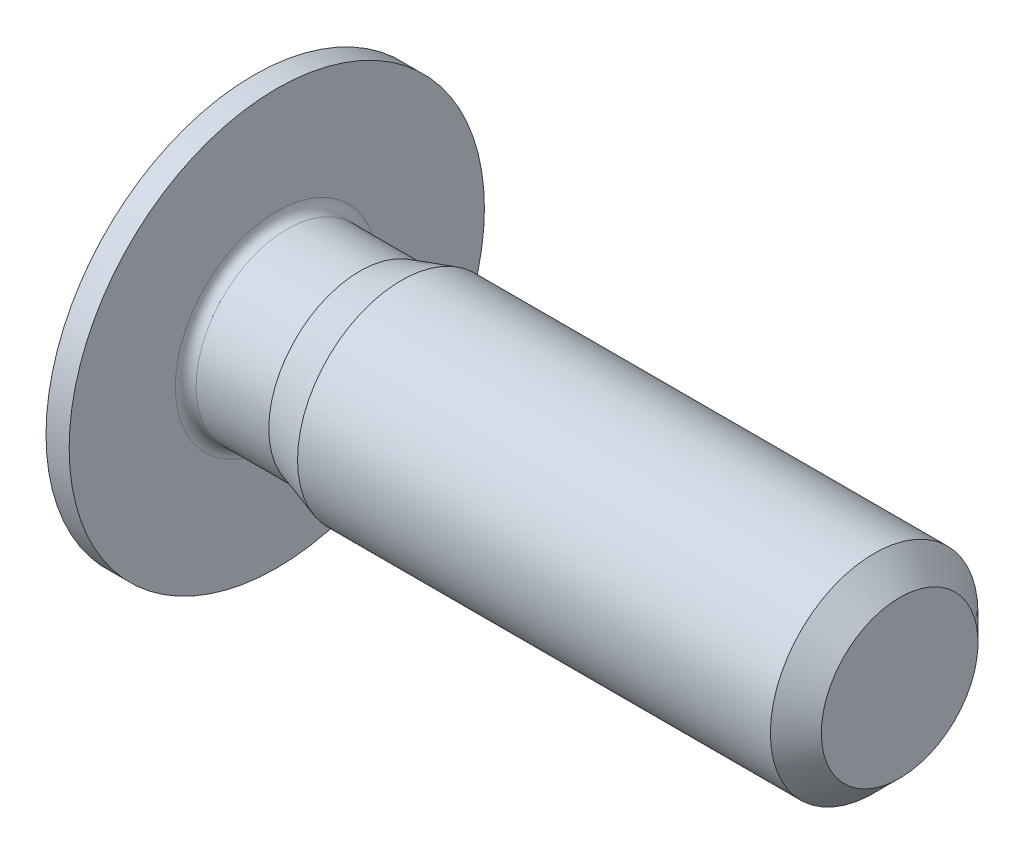
from build123d import *

# Parameters (mm, degrees)
CUT_EXTRUDE1_DEPTH = 1.2


with BuildPart() as part:
    # Sketch1 → Revolve1 (revolve)
    with BuildSketch(Plane.XY):
        with BuildLine():
            Line((-0.5, 0), (-0.5, 1.52))
            Line((-0.5, 1.52), (-0.222871871, 2))
            Line((-0.222871871, 2), (0, 2))
            Line((0, 2), (0, 0.97725))
            ThreePointArc((0, 0.97725), (0.029289322, 0.906539322), (0.1, 0.87725))
            Line((0.1, 0.87725), (0.8, 0.87725))
            Line((0.8, 0.87725), (1.2, 1))
            Line((1.2, 1), (5.7545, 1))
            Line((5.7545, 1), (6, 0.7545))
            Line((6, 0.7545), (6, 0))
            Line((6, 0), (-0.5, 0))
        make_face()
    revolve(axis=Axis((6, 0, 0), (-1, 0, 0)))

    # Sketch2 → Cut-Revolve1 (revolve, cut)
    with BuildSketch(Plane.XY):
        Polygon((-0.5, 0), (-0.5, 0.65), (0.7, 0.65), (1.075277675, 0), align=None)
    revolve(axis=Axis((1.075277675, 0, 0), (-1, 0, 0)), mode=Mode.SUBTRACT)

    # Sketch3 → Cut-Extrude1 (cut)
    with BuildSketch(Plane(origin=(-0.5, 0, 0), x_dir=(0, 0, -1), z_dir=(1, 0, 0))):
        Polygon((-0.65, -0.375277675), (0, -0.75055535), (0.65, -0.375277675), (0.65, 0.375277675), (0, 0.75055535), (-0.65, 0.375277675), align=None)
    extrude(amount=CUT_EXTRUDE1_DEPTH, mode=Mode.SUBTRACT)


solid = part.part
